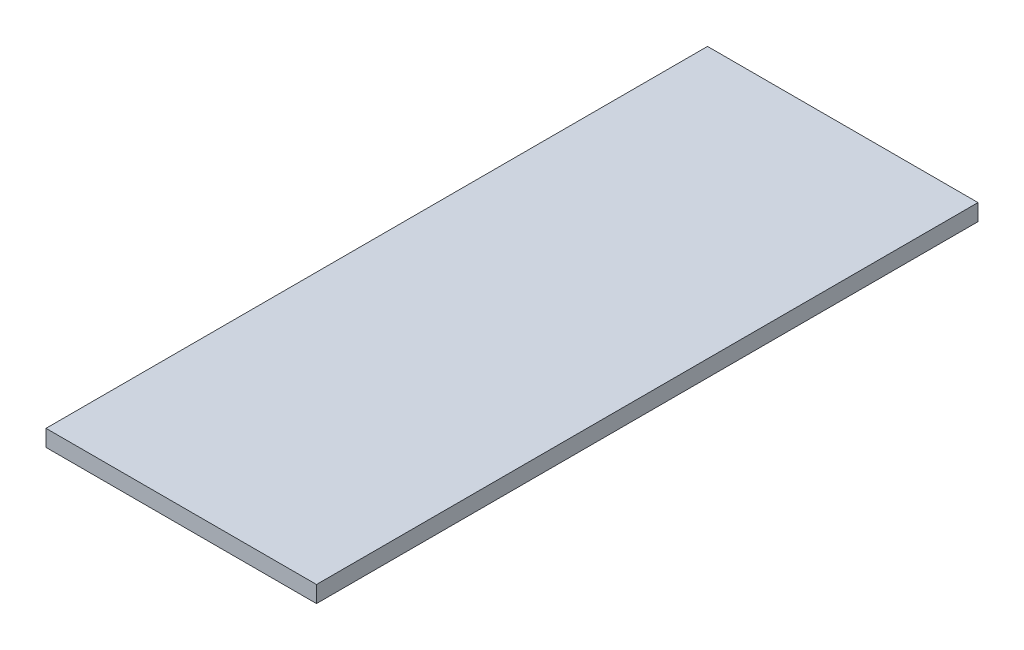
from build123d import *

# Parameters (mm, degrees)
SKETCH_1_W      = 294
SKETCH_1_H      = 719
EXTRUDE_1_DEPTH = 18


with BuildPart() as part:
    # Эскиз1 → Бобышка-Вытянуть1 (new body)
    with BuildSketch(Plane(origin=(0, 0, 0), x_dir=(1, 0, 0), z_dir=(0, 1, 0))):
        Rectangle(SKETCH_1_W, SKETCH_1_H)
    extrude(amount=EXTRUDE_1_DEPTH)


solid = part.part
